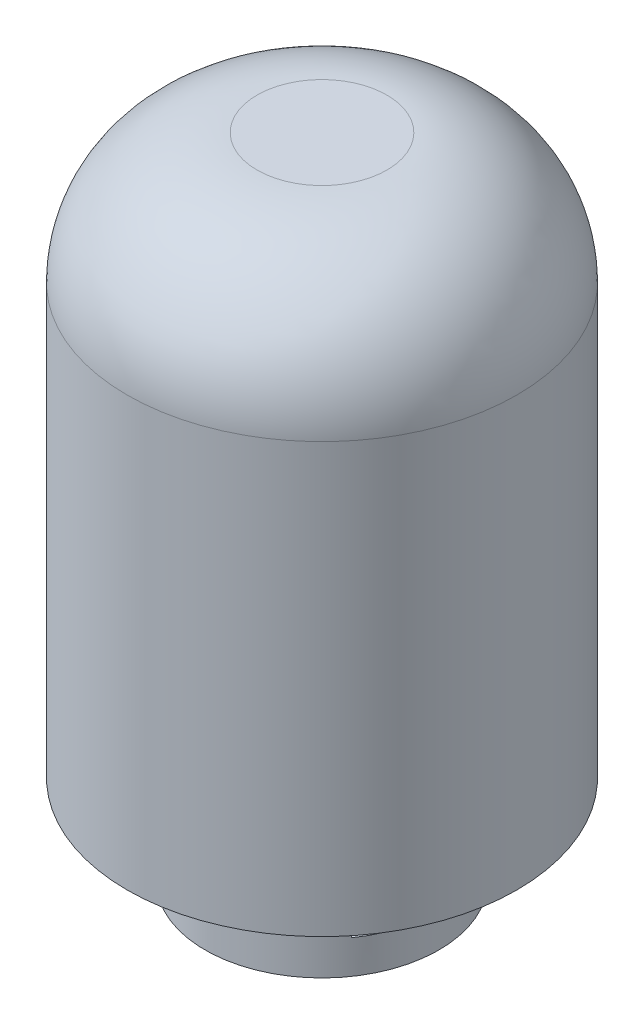
from build123d import *

# Parameters (mm, degrees)
SKETCH1_R               = 150
BOSS_EXTRUDE1_DEPTH     = 500
SKETCH2_R               = 150
SKETCH2_R_2             = 90
CUT_EXTRUDE1_DEPTH      = 70
SKETCH3_W               = 102.450978838
SKETCH3_H               = 18.366336908
CUT_EXTRUDE2_DEPTH      = 151
CUT_EXTRUDE2_DEPTH_BACK = 151
FILLET1_R               = 100
SKETCH4_R               = 67.5
CUT_EXTRUDE3_DEPTH      = 151


with BuildPart() as part:
    # Sketch1 → Boss-Extrude1 (new body)
    with BuildSketch(Plane(origin=(0, 0, 0), x_dir=(1, 0, 0), z_dir=(0, 1, 0))):
        Circle(SKETCH1_R)
    extrude(amount=BOSS_EXTRUDE1_DEPTH)

    # Sketch2 → Cut-Extrude1 (cut)
    with BuildSketch(Plane.XZ):
        Circle(SKETCH2_R)
        Circle(SKETCH2_R_2, mode=Mode.SUBTRACT)
    extrude(amount=-CUT_EXTRUDE1_DEPTH, mode=Mode.SUBTRACT)

    # Sketch3 → Cut-Extrude2 (cut, two sides)
    with BuildSketch(Plane(origin=(0, 0, 0), x_dir=(0, 0, -1), z_dir=(1, 0, 0))) as cut_extrude2_sk:
        with Locations((0, 35)):
            Rectangle(SKETCH3_W, SKETCH3_H)
    extrude(amount=CUT_EXTRUDE2_DEPTH, mode=Mode.SUBTRACT)
    extrude(cut_extrude2_sk.sketch, amount=-CUT_EXTRUDE2_DEPTH_BACK, mode=Mode.SUBTRACT)

    # Fillet1
    fillet1_edges = [part.edges().sort_by_distance(p)[0] for p in [
        (-150, 500, 0),
    ]]
    fillet(fillet1_edges, radius=FILLET1_R)

    # Sketch4 → Cut-Extrude3 (cut, through all)
    with BuildSketch(Plane.XY):
        with Locations((0, 249.430268714)):
            Circle(SKETCH4_R)
    extrude(amount=-CUT_EXTRUDE3_DEPTH, mode=Mode.SUBTRACT)


solid = part.part
